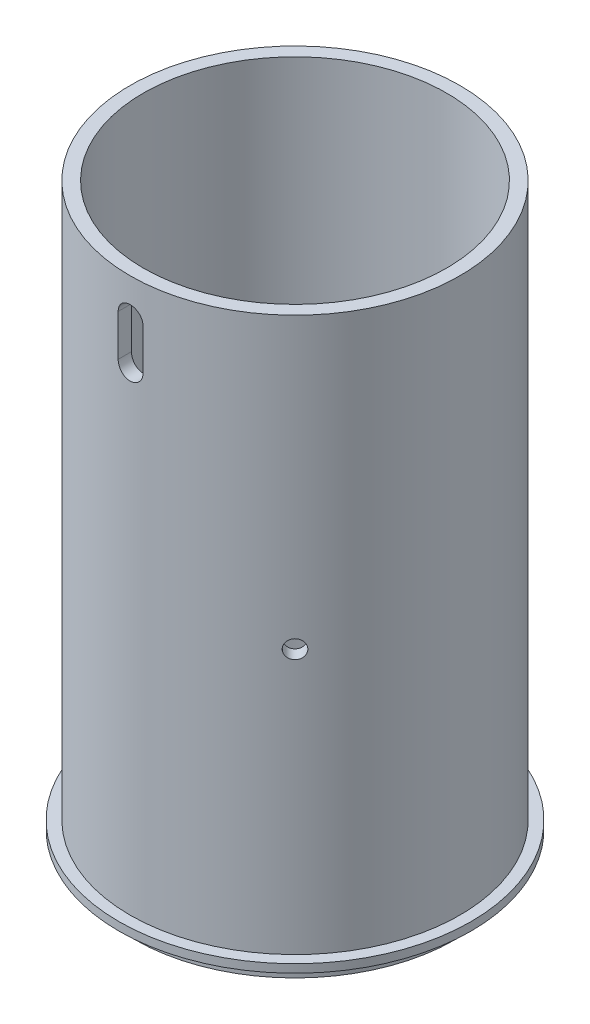
from build123d import *

# Parameters (mm, degrees)
SKETCH1_R                       = 24.5999
SKETCH1_R_2                     = 18.2245
BOSS_EXTRUDE1_DEPTH             = 4.3942
SKETCH2_R                       = 25.3365
SKETCH2_R_2                     = 18.2245
BOSS_EXTRUDE2_DEPTH             = 33.02
SKETCH15_R                      = 27.051
SKETCH15_R_2                    = 25.3365
BOSS_EXTRUDE3_DEPTH             = 1.27
SKETCH18_R                      = 25.3365
SKETCH18_R_2                    = 23.3045
BOSS_EXTRUDE5_DEPTH             = 53.34
CUT_EXTRUDE2_DEPTH              = 10.16
F_35_0_11_DIAMETER_HOLE1_REACH  = 112.817
F_35_0_11_DIAMETER_HOLE1_BORE_R = 1.397
CIRPATTERN1_COUNT               = 4
MOVE_FACE1_BY                   = 2.032
MOVE_FACE2_BY                   = 5.08


with BuildPart() as part:
    # Sketch1 → Boss-Extrude1 (new body)
    with BuildSketch(Plane(origin=(0, 0, 0), x_dir=(1, 0, 0), z_dir=(0, 1, 0))):
        with Locations(Location((0, 0, 0), (0, 0, 270))):
            Circle(SKETCH1_R)
        with Locations(Location((0, 0, 0), (0, 0, 270))):
            Circle(SKETCH1_R_2, mode=Mode.SUBTRACT)
    extrude(amount=BOSS_EXTRUDE1_DEPTH)

    # Sketch2 → Boss-Extrude2 (add)
    with BuildSketch(Plane(origin=(0, 4.3942, 0), x_dir=(1, 0, 0), z_dir=(0, 1, 0))):
        with Locations(Location((0, 0, 0), (0, 0, 270))):
            Circle(SKETCH2_R)
        with Locations(Location((0, 0, 0), (0, 0, 270))):
            Circle(SKETCH2_R_2, mode=Mode.SUBTRACT)
    extrude(amount=BOSS_EXTRUDE2_DEPTH)

    # Sketch15 → Boss-Extrude3 (add)
    with BuildSketch(Plane.XZ.offset(-4.3942)):
        with Locations(Location((0, 0, 0), (0, 0, 270))):
            Circle(SKETCH15_R)
        with Locations(Location((0, 0, 0), (0, 0, 270))):
            Circle(SKETCH15_R_2, mode=Mode.SUBTRACT)
    extrude(amount=-BOSS_EXTRUDE3_DEPTH)

    # Sketch18 → Boss-Extrude5 (add)
    with BuildSketch(Plane(origin=(0, 37.4142, 0), x_dir=(1, 0, 0), z_dir=(0, 1, 0))):
        with Locations(Location((0, 0, 0), (0, 0, 90))):
            Circle(SKETCH18_R)
        with Locations(Location((0, 0, 0), (0, 0, 270))):
            Circle(SKETCH18_R_2, mode=Mode.SUBTRACT)
    extrude(amount=BOSS_EXTRUDE5_DEPTH)

    # Sketch19 → Cut-Extrude2 (cut)
    with BuildSketch(Plane.XY.offset(25.3365)):
        with BuildLine():
            Line((1.905, 85.025248354), (1.905, 78.649848354))
            ThreePointArc((1.905, 78.649848354), (0, 76.744848354), (-1.905, 78.649848354))
            Line((-1.905, 78.649848354), (-1.905, 85.025248354))
            ThreePointArc((-1.905, 85.025248354), (0, 86.930248354), (1.905, 85.025248354))
        make_face()
    extrude(amount=-CUT_EXTRUDE2_DEPTH, mode=Mode.SUBTRACT)

    # #35 (0.11) Diameter Hole1 bore → #35 (0.11) Diameter Hole1 (cut, up to next)
    with BuildSketch(Plane(origin=(-17.915610962, 0, 17.915610962), x_dir=(0, -1, 0), z_dir=(-0.7071067811865488, 0, 0.7071067811865464)), mode=Mode.PRIVATE) as f_35_0_11_diameter_hole1_sk1:
        with Locations((-46.3042, 0)):
            Circle(F_35_0_11_DIAMETER_HOLE1_BORE_R)
    f_35_0_11_diameter_hole1_tool1 = extrude(f_35_0_11_diameter_hole1_sk1.sketch, amount=-F_35_0_11_DIAMETER_HOLE1_REACH, mode=Mode.PRIVATE) & part.part
    f_35_0_11_diameter_hole1 = f_35_0_11_diameter_hole1_tool1.solids().sort_by_distance((-17.915611, 46.3042, 17.915611))[0]
    add(f_35_0_11_diameter_hole1, mode=Mode.SUBTRACT)

    # CirPattern1: #35 (0.11) Diameter Hole1 ×4 about axis
    cirpattern1_axis = Axis((0, 37.4142, 0), (0, -1, 0))
    for i in range(1, CIRPATTERN1_COUNT):
        add(f_35_0_11_diameter_hole1.rotate(cirpattern1_axis, i * 360 / CIRPATTERN1_COUNT), mode=Mode.SUBTRACT)

    # Move Face1: a face moved inward by 2.032
    extrude(part.faces().sort_by_distance((0, 0, 19.67992))[0], amount=MOVE_FACE1_BY, dir=(0, 1, 0), mode=Mode.SUBTRACT)

    # Move Face2: a face moved inward by 5.08
    extrude(part.faces().sort_by_distance((0, 37.4142, 18.6436))[0], amount=MOVE_FACE2_BY, dir=(0, -1, 0), mode=Mode.SUBTRACT)


solid = part.part
